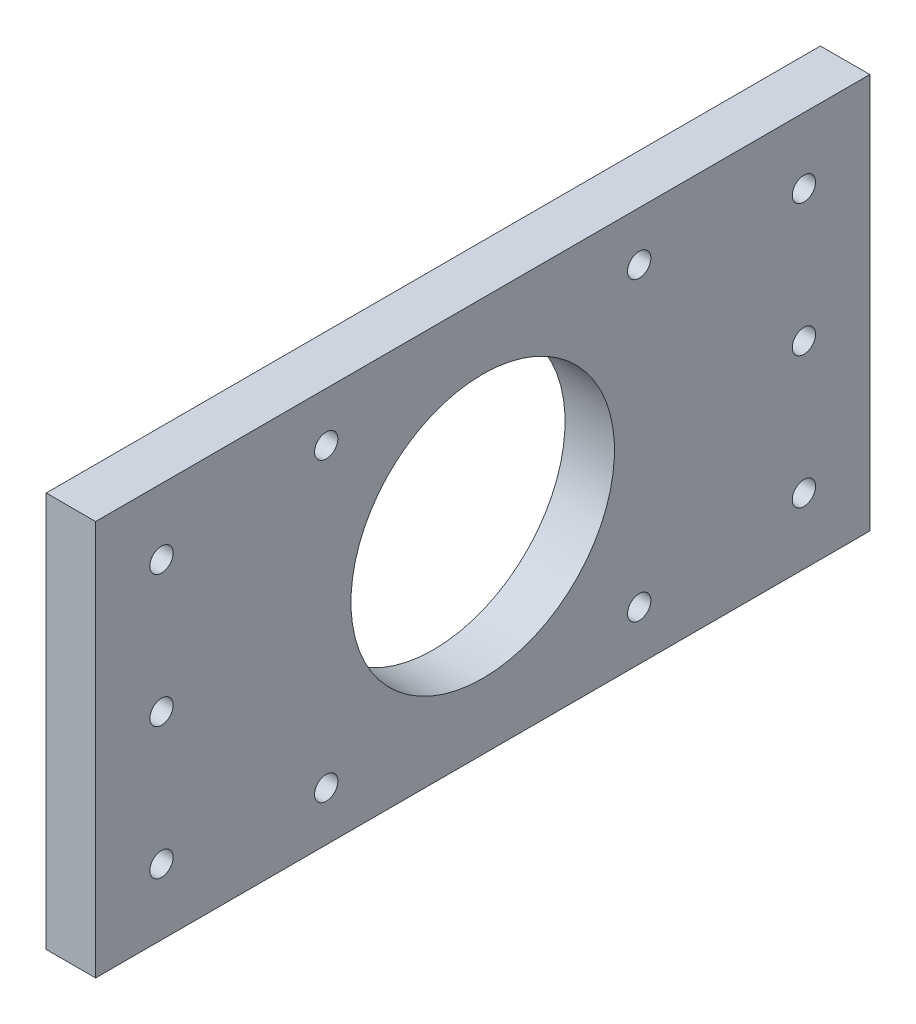
from build123d import *

# Parameters (mm, degrees)
SKETCH1_W             = 9.525
SKETCH1_H             = 76.2
BOSS_EXTRUDE1_DEPTH   = 149.225
F_8_CLEARANCE_HOLE1_D = 4.4958
F_8_CLEARANCE_HOLE2_D = 4.4958
SKETCH6_R             = 25.4
CUT_EXTRUDE1_DEPTH    = 10.525


with BuildPart() as part:
    # Sketch1 → Boss-Extrude1 (new body)
    with BuildSketch(Plane.XY):
        Rectangle(SKETCH1_W, SKETCH1_H)
    extrude(amount=BOSS_EXTRUDE1_DEPTH)

    # #8 Clearance Hole1 (through all)
    with Locations(Plane(origin=(4.7625, 0, 0), x_dir=(0, 0, -1), z_dir=(1, 0, 0))):
        with Locations((-44.45, -28.575), (-104.775, 28.575), (-104.775, -28.575), (-44.45, 28.575)):
            Hole(F_8_CLEARANCE_HOLE1_D / 2)

    # #8 Clearance Hole2 (through all)
    with Locations(Plane(origin=(4.7625, 0, 0), x_dir=(0, 0, -1), z_dir=(1, 0, 0))):
        with Locations((-136.525, 25.4), (-136.525, 0), (-136.525, -25.4), (-12.7, 25.4), (-12.7, 0), (-12.7, -25.4)):
            Hole(F_8_CLEARANCE_HOLE2_D / 2)

    # Sketch6 → Cut-Extrude1 (cut, through all)
    with BuildSketch(Plane(origin=(4.7625, 0, 0), x_dir=(0, 0, -1), z_dir=(1, 0, 0))):
        with Locations(Location((-74.6125, 0, 0), (0, 0, 90))):  # turned: the seam where the file's is
            Circle(SKETCH6_R)
    extrude(amount=-CUT_EXTRUDE1_DEPTH, mode=Mode.SUBTRACT)


solid = part.part
